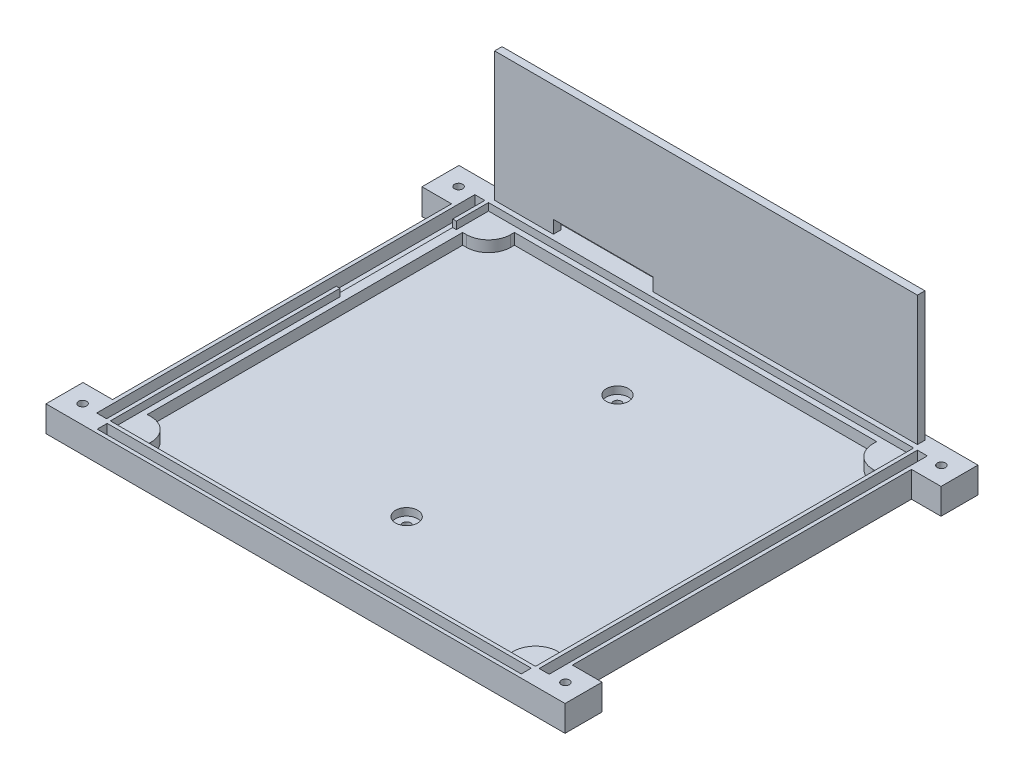
from build123d import *

# Parameters (mm, degrees)
SKETCH1_W            = 124.4
SKETCH1_H            = 111.7
BOSS_EXTRUDE1_DEPTH  = 15.65
FILLET1_R            = 2
SKETCH4_W            = 115
SKETCH4_H            = 102.3
CUT_EXTRUDE1_DEPTH   = 2
SKETCH5_W            = 112
SKETCH5_H            = 99.3
CUT_EXTRUDE2_DEPTH   = 3
SKETCH10_W           = 7
SKETCH10_H           = 7
BOSS_EXTRUDE2_DEPTH  = 3
BOSS_EXTRUDE5_DEPTH  = 35
FILLET3_R            = 6
SKETCH32_W           = 114.7
SKETCH32_H           = 2.7
SKETCH32_W_2         = 2.7
SKETCH32_H_2         = 102.3
CUT_EXTRUDE7_DEPTH   = 3.5
SKETCH29_W           = 27
SKETCH29_H           = 3.5
CUT_EXTRUDE8_DEPTH   = 112.7
SKETCH34_W           = 1
SKETCH34_H           = 31.5
CUT_EXTRUDE9_DEPTH   = 2
SKETCH39_W           = 124.4
SKETCH39_H           = 111.7
CUT_EXTRUDE14_DEPTH  = 8.65
SKETCH40_W           = 10.736913624
SKETCH40_H           = 4.7
BOSS_EXTRUDE8_DEPTH  = 7
SKETCH42_W           = 6.036913624
SKETCH42_H           = 2.116828075
BOSS_EXTRUDE9_DEPTH  = 7
SKETCH43_W           = 2
SKETCH43_H           = 3.979386742
BOSS_EXTRUDE10_DEPTH = 7
SKETCH44_W           = 10.013933806
SKETCH44_H           = 10.028001726
BOSS_EXTRUDE11_DEPTH = 7
SKETCH45_R           = 1.1
CUT_EXTRUDE15_DEPTH  = 8
SKETCH46_W           = 2
SKETCH46_H           = 2
BOSS_EXTRUDE12_DEPTH = 7
SKETCH47_W           = 2
SKETCH47_H           = 2
BOSS_EXTRUDE13_DEPTH = 7
SKETCH48_W           = 10
SKETCH48_H           = 10
BOSS_EXTRUDE14_DEPTH = 7
SKETCH49_R           = 1.1
SKETCH49_W           = 6.036913624
SKETCH49_H           = 6.816828075
CUT_EXTRUDE18_DEPTH  = 7
SKETCH50_W           = 8
SKETCH50_H           = 10
BOSS_EXTRUDE17_DEPTH = 7
SKETCH51_W           = 5.24842793
SKETCH51_H           = 4.514776714
BOSS_EXTRUDE18_DEPTH = 7
SKETCH52_W           = 2
SKETCH52_H           = 10
CUT_EXTRUDE19_DEPTH  = 7
SKETCH53_W           = 10.013933806
SKETCH53_H           = 10.028001726
CUT_EXTRUDE20_DEPTH  = 7
SKETCH54_W           = 8
SKETCH54_H           = 10
BOSS_EXTRUDE19_DEPTH = 7
SKETCH55_W           = 8
SKETCH55_H           = 10
BOSS_EXTRUDE20_DEPTH = 7
SKETCH56_R           = 1.1
CUT_EXTRUDE21_DEPTH  = 7
SKETCH57_R           = 1.1
CUT_EXTRUDE22_DEPTH  = 7
SKETCH58_R           = 1.1
CUT_EXTRUDE23_DEPTH  = 7
SKETCH59_R           = 1.1
CUT_EXTRUDE24_DEPTH  = 7
SKETCH61_W           = 20.033048375
SKETCH61_H           = 15
SKETCH61_W_2         = 20.00121795
BOSS_EXTRUDE22_DEPTH = 8
SKETCH64_R           = 1.1
CUT_EXTRUDE27_DEPTH  = 51
SKETCH65_R           = 3
CUT_EXTRUDE28_DEPTH  = 2


with BuildPart() as part:
    # Sketch1 → Boss-Extrude1 (new body)
    with BuildSketch(Plane(origin=(0, 0, 0), x_dir=(1, 0, 0), z_dir=(0, 1, 0))):
        with Locations((62.2, 55.85)):
            Rectangle(SKETCH1_W, SKETCH1_H)
    extrude(amount=BOSS_EXTRUDE1_DEPTH)

    # Fillet1
    fillet1_edges = [part.edges().sort_by_distance(p)[0] for p in [
        (0, 7.825, -111.7),
        (124.4, 7.825, -111.7),
        (124.4, 7.825, 0),
        (0, 7.825, 0),
    ]]
    fillet(fillet1_edges, radius=FILLET1_R)

    # Sketch4 → Cut-Extrude1 (cut)
    with BuildSketch(Plane(origin=(0, 15.65, 0), x_dir=(1, 0, 0), z_dir=(0, 1, 0))):
        with Locations((62.2, 55.85)):
            Rectangle(SKETCH4_W, SKETCH4_H)
    extrude(amount=-CUT_EXTRUDE1_DEPTH, mode=Mode.SUBTRACT)

    # Sketch5 → Cut-Extrude2 (cut)
    with BuildSketch(Plane(origin=(0, 13.65, 0), x_dir=(1, 0, 0), z_dir=(0, 1, 0))):
        with Locations((62.2, 55.85)):
            Rectangle(SKETCH5_W, SKETCH5_H)
    extrude(amount=-CUT_EXTRUDE2_DEPTH, mode=Mode.SUBTRACT)

    # Sketch10 → Boss-Extrude2 (add)
    with BuildSketch(Plane(origin=(0, 10.65, 0), x_dir=(1, 0, 0), z_dir=(0, 1, 0))):
        with Locations((9.7, 102)):
            Rectangle(SKETCH10_W, SKETCH10_H)
        with Locations((9.7, 9.7)):
            Rectangle(SKETCH10_W, SKETCH10_H)
        with Locations((114.7, 102)):
            Rectangle(SKETCH10_W, SKETCH10_H)
        with Locations((114.7, 9.7)):
            Rectangle(SKETCH10_W, SKETCH10_H)
    extrude(amount=BOSS_EXTRUDE2_DEPTH)

    # Sketch27 → Boss-Extrude5 (add)
    with BuildSketch(Plane(origin=(0, 15.65, 0), x_dir=(1, 0, 0), z_dir=(0, 1, 0))):
        Polygon((5, 110.35), (119.4, 110.35), (119.4, 108.316244658), (5, 108.35), align=None)
    extrude(amount=BOSS_EXTRUDE5_DEPTH)

    # Fillet3
    fillet3_edges = [part.edges().sort_by_distance(p)[0] for p in [
        (111.2, 12.15, -13.2),
        (13.2, 12.15, -98.5),
        (13.2, 12.15, -13.2),
        (111.2, 12.15, -98.5),
    ]]
    fillet(fillet3_edges, radius=FILLET3_R)

    # Sketch32 → Cut-Extrude7 (cut)
    with BuildSketch(Plane(origin=(0, 15.65, 0), x_dir=(1, 0, 0), z_dir=(0, 1, 0))):
        with Locations((62.2, 2.35)):
            Rectangle(SKETCH32_W, SKETCH32_H)
        with Locations((2.35, 55.85)):
            Rectangle(SKETCH32_W_2, SKETCH32_H_2)
        with Locations((122.05, 55.85)):
            Rectangle(SKETCH32_W_2, SKETCH32_H_2)
    extrude(amount=-CUT_EXTRUDE7_DEPTH, mode=Mode.SUBTRACT)

    # Sketch29 → Cut-Extrude8 (cut, through all)
    with BuildSketch(Plane(origin=(0, 0, -111.7), x_dir=(-1, 0, 0), z_dir=(0, 0, -1))):
        with Locations((-34.4, 17.4)):
            Rectangle(SKETCH29_W, SKETCH29_H)
    extrude(amount=-CUT_EXTRUDE8_DEPTH, mode=Mode.SUBTRACT)

    # Sketch34 → Cut-Extrude9 (cut)
    with BuildSketch(Plane(origin=(0, 15.65, 0), x_dir=(1, 0, 0), z_dir=(0, 1, 0))):
        with Locations((4.2, 82.55)):
            Rectangle(SKETCH34_W, SKETCH34_H)
    extrude(amount=-CUT_EXTRUDE9_DEPTH, mode=Mode.SUBTRACT)

    # Sketch39 → Cut-Extrude14 (cut)
    with BuildSketch(Plane(origin=(0, 0, 0), x_dir=(-1, 0, 0), z_dir=(0, -1, 0))):
        with Locations((-62.2, 55.85)):
            Rectangle(SKETCH39_W, SKETCH39_H)
    extrude(amount=-CUT_EXTRUDE14_DEPTH, mode=Mode.SUBTRACT)

    # Sketch40 → Boss-Extrude8 (add)
    with BuildSketch(Plane(origin=(0, 15.65, 0), x_dir=(1, 0, 0), z_dir=(0, 1, 0))):
        with Locations((-0.668456812, 2.35)):
            Rectangle(SKETCH40_W, SKETCH40_H)
    extrude(amount=-BOSS_EXTRUDE8_DEPTH)

    # Sketch42 → Boss-Extrude9 (add)
    with BuildSketch(Plane(origin=(0, 15.65, 0), x_dir=(1, 0, 0), z_dir=(0, 1, 0))):
        with Locations((-3.018456812, 5.758414037)):
            Rectangle(SKETCH42_W, SKETCH42_H)
    extrude(amount=-BOSS_EXTRUDE9_DEPTH)

    # Sketch43 → Boss-Extrude10 (add)
    with BuildSketch(Plane(origin=(0, 15.65, 0), x_dir=(1, 0, 0), z_dir=(0, 1, 0))):
        with Locations((123.4, 1.989693371)):
            Rectangle(SKETCH43_W, SKETCH43_H)
    extrude(amount=-BOSS_EXTRUDE10_DEPTH)

    # Sketch44 → Boss-Extrude11 (add)
    with BuildSketch(Plane(origin=(0, 15.65, 0), x_dir=(1, 0, 0), z_dir=(0, 1, 0))):
        with Locations((129.406966903, 5.014000863)):
            Rectangle(SKETCH44_W, SKETCH44_H)
    extrude(amount=-BOSS_EXTRUDE11_DEPTH)

    # Sketch45 → Cut-Extrude15 (cut, through all)
    with BuildSketch(Plane(origin=(0, 15.65, 0), x_dir=(1, 0, 0), z_dir=(0, 1, 0))):
        with Locations((129.4, 5)):
            Circle(SKETCH45_R)
    extrude(amount=-CUT_EXTRUDE15_DEPTH, mode=Mode.SUBTRACT)

    # Sketch46 → Boss-Extrude12 (add)
    with BuildSketch(Plane(origin=(0, 15.65, 0), x_dir=(1, 0, 0), z_dir=(0, 1, 0))):
        with Locations((123.4, 110.7)):
            Rectangle(SKETCH46_W, SKETCH46_H)
    extrude(amount=-BOSS_EXTRUDE12_DEPTH)

    # Sketch47 → Boss-Extrude13 (add)
    with BuildSketch(Plane(origin=(0, 15.65, 0), x_dir=(1, 0, 0), z_dir=(0, 1, 0))):
        with Locations((1, 110.7)):
            Rectangle(SKETCH47_W, SKETCH47_H)
    extrude(amount=-BOSS_EXTRUDE13_DEPTH)

    # Sketch48 → Boss-Extrude14 (add)
    with BuildSketch(Plane(origin=(0, 15.65, 0), x_dir=(1, 0, 0), z_dir=(0, 1, 0))):
        with Locations((-5, 106.7)):
            Rectangle(SKETCH48_W, SKETCH48_H)
    extrude(amount=-BOSS_EXTRUDE14_DEPTH)

    # Sketch49 → Cut-Extrude18 (cut)
    with BuildSketch(Plane(origin=(0, 15.65, 0), x_dir=(1, 0, 0), z_dir=(0, 1, 0))):
        with Locations((-5, 106.7)):
            Circle(SKETCH49_R)
        with Locations((-3.018456812, 3.408414038)):
            Rectangle(SKETCH49_W, SKETCH49_H)
    extrude(amount=-CUT_EXTRUDE18_DEPTH, mode=Mode.SUBTRACT)

    # Sketch50 → Boss-Extrude17 (add)
    with BuildSketch(Plane(origin=(0, 15.65, 0), x_dir=(1, 0, 0), z_dir=(0, 1, 0))):
        with Locations((-4, 5)):
            Rectangle(SKETCH50_W, SKETCH50_H)
    extrude(amount=-BOSS_EXTRUDE17_DEPTH)

    # Sketch51 → Boss-Extrude18 (add)
    with BuildSketch(Plane(origin=(0, 15.65, 0), x_dir=(1, 0, 0), z_dir=(0, 1, 0))):
        with Locations((-4.818404413, 107.053945145)):
            Rectangle(SKETCH51_W, SKETCH51_H)
    extrude(amount=-BOSS_EXTRUDE18_DEPTH)

    # Sketch52 → Cut-Extrude19 (cut)
    with BuildSketch(Plane(origin=(0, 15.65, 0), x_dir=(1, 0, 0), z_dir=(0, 1, 0))):
        with Locations((-9, 106.7)):
            Rectangle(SKETCH52_W, SKETCH52_H)
    extrude(amount=-CUT_EXTRUDE19_DEPTH, mode=Mode.SUBTRACT)

    # Sketch53 → Cut-Extrude20 (cut)
    with BuildSketch(Plane(origin=(0, 15.65, 0), x_dir=(1, 0, 0), z_dir=(0, 1, 0))):
        with Locations((129.406966903, 5.014000863)):
            Rectangle(SKETCH53_W, SKETCH53_H)
    extrude(amount=-CUT_EXTRUDE20_DEPTH, mode=Mode.SUBTRACT)

    # Sketch54 → Boss-Extrude19 (add)
    with BuildSketch(Plane(origin=(0, 15.65, 0), x_dir=(1, 0, 0), z_dir=(0, 1, 0))):
        with Locations((128.4, 5)):
            Rectangle(SKETCH54_W, SKETCH54_H)
    extrude(amount=-BOSS_EXTRUDE19_DEPTH)

    # Sketch55 → Boss-Extrude20 (add)
    with BuildSketch(Plane(origin=(0, 15.65, 0), x_dir=(1, 0, 0), z_dir=(0, 1, 0))):
        with Locations((128.4, 106.7)):
            Rectangle(SKETCH55_W, SKETCH55_H)
    extrude(amount=-BOSS_EXTRUDE20_DEPTH)

    # Sketch56 → Cut-Extrude21 (cut)
    with BuildSketch(Plane(origin=(0, 15.65, 0), x_dir=(1, 0, 0), z_dir=(0, 1, 0))):
        with Locations((-3.1, 106.7)):
            Circle(SKETCH56_R)
    extrude(amount=-CUT_EXTRUDE21_DEPTH, mode=Mode.SUBTRACT)

    # Sketch57 → Cut-Extrude22 (cut)
    with BuildSketch(Plane(origin=(0, 15.65, 0), x_dir=(1, 0, 0), z_dir=(0, 1, 0))):
        with Locations((-3.1, 5)):
            Circle(SKETCH57_R)
    extrude(amount=-CUT_EXTRUDE22_DEPTH, mode=Mode.SUBTRACT)

    # Sketch58 → Cut-Extrude23 (cut)
    with BuildSketch(Plane(origin=(0, 15.65, 0), x_dir=(1, 0, 0), z_dir=(0, 1, 0))):
        with Locations((127.5, 5)):
            Circle(SKETCH58_R)
    extrude(amount=-CUT_EXTRUDE23_DEPTH, mode=Mode.SUBTRACT)

    # Sketch59 → Cut-Extrude24 (cut)
    with BuildSketch(Plane(origin=(0, 15.65, 0), x_dir=(1, 0, 0), z_dir=(0, 1, 0))):
        with Locations((127.5, 106.7)):
            Circle(SKETCH59_R)
    extrude(amount=-CUT_EXTRUDE24_DEPTH, mode=Mode.SUBTRACT)

    # Sketch61 → Boss-Extrude22 (add)
    with BuildSketch(Plane.XZ.offset(-8.65)):
        with Locations((62.216524188, -84.35)):
            Rectangle(SKETCH61_W, SKETCH61_H)
        with Locations((62.200608975, -27.35)):
            Rectangle(SKETCH61_W_2, SKETCH61_H)
    extrude(amount=BOSS_EXTRUDE22_DEPTH)

    # Sketch64 → Cut-Extrude27 (cut, through all)
    with BuildSketch(Plane(origin=(0, 0.65, 0), x_dir=(-1, 0, 0), z_dir=(0, -1, 0))):
        with Locations((-62.216524187, 84.35)):
            Circle(SKETCH64_R)
        with Locations((-62.200608975, 27.35)):
            Circle(SKETCH64_R)
    extrude(amount=-CUT_EXTRUDE27_DEPTH, mode=Mode.SUBTRACT)

    # Sketch65 → Cut-Extrude28 (cut)
    with BuildSketch(Plane(origin=(0, 10.65, 0), x_dir=(1, 0, 0), z_dir=(0, 1, 0))):
        with Locations((62.200608975, 27.35)):
            Circle(SKETCH65_R)
        with Locations((62.216524187, 84.35)):
            Circle(SKETCH65_R)
    extrude(amount=-CUT_EXTRUDE28_DEPTH, mode=Mode.SUBTRACT)


solid = part.part
